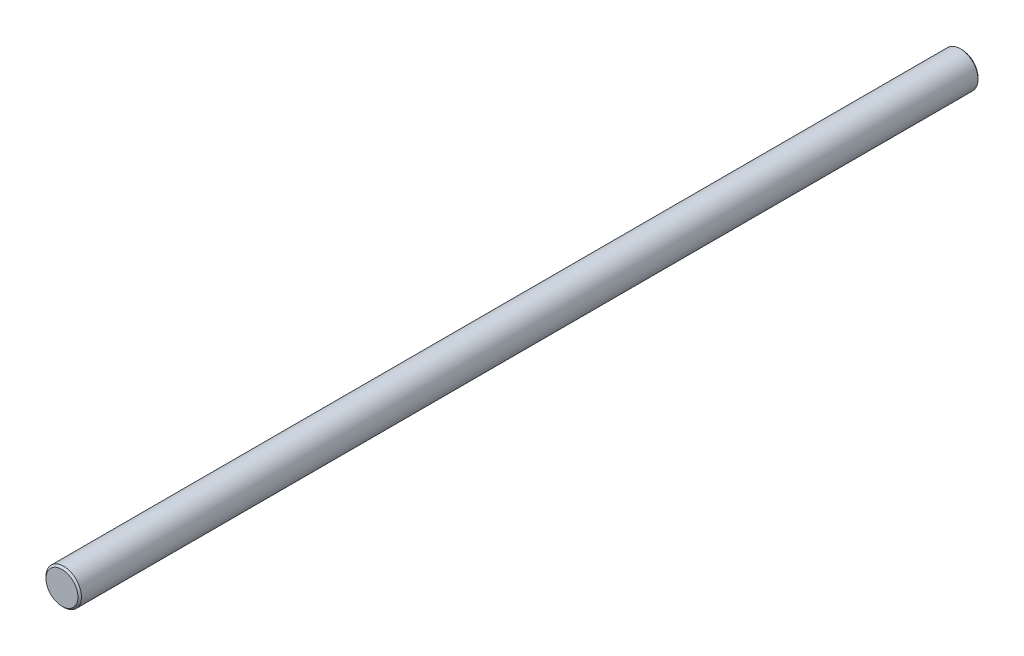
from build123d import *

# Parameters (mm, degrees)
SKETCH1_R           = 10
BOSS_EXTRUDE1_DEPTH = 507
CHAMFER1_SIZE       = 1


with BuildPart() as part:
    # Sketch1 → Boss-Extrude1 (new body)
    with BuildSketch(Plane.XY):
        Circle(SKETCH1_R)
    extrude(amount=BOSS_EXTRUDE1_DEPTH)

    # Chamfer1
    chamfer1_edges = [part.edges().sort_by_distance(p)[0] for p in [
        (-10, 0, 0),
        (-10, 0, 507),
    ]]
    chamfer(chamfer1_edges, length=CHAMFER1_SIZE)


solid = part.part
